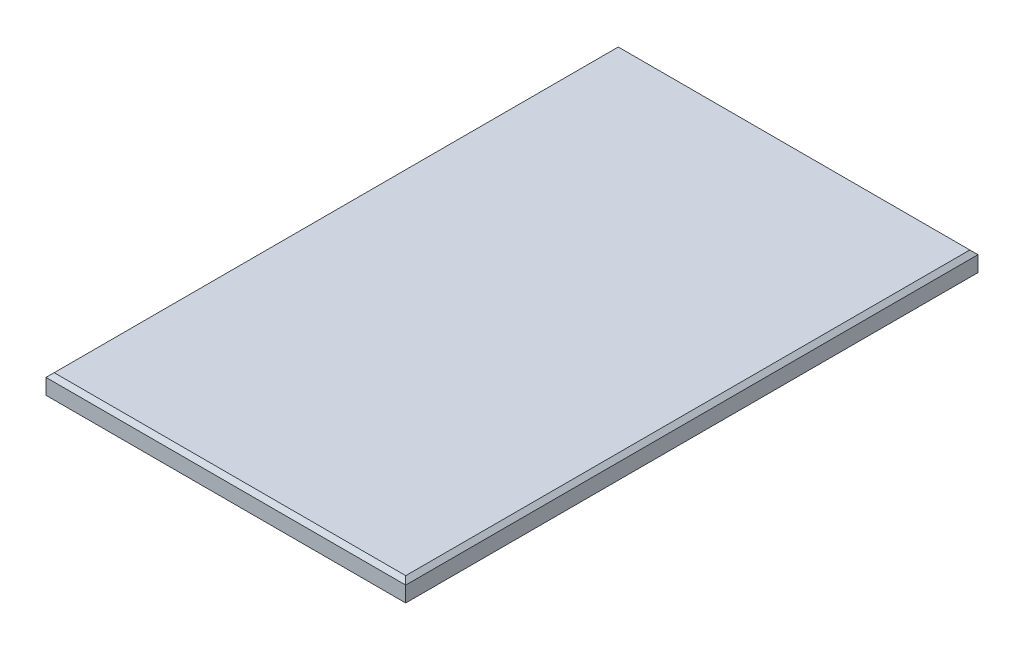
from build123d import *

# Parameters (mm, degrees)
SKETCH1_W           = 22
SKETCH1_H           = 35
BOSS_EXTRUDE1_DEPTH = 1.2
CHAMFER1_SIZE       = 0.25


with BuildPart() as part:
    # Sketch1 → Boss-Extrude1 (new body)
    with BuildSketch(Plane(origin=(0, 0, 0), x_dir=(1, 0, 0), z_dir=(0, 1, 0))):
        with Locations((11, 17.5)):
            Rectangle(SKETCH1_W, SKETCH1_H)
    extrude(amount=BOSS_EXTRUDE1_DEPTH)

    # Chamfer1
    chamfer1_edges = [part.edges().sort_by_distance(p)[0] for p in [
        (22, 1.2, -17.5),
        (11, 1.2, -35),
        (0, 1.2, -17.5),
        (11, 1.2, 0),
    ]]
    chamfer(chamfer1_edges, length=CHAMFER1_SIZE)


solid = part.part
